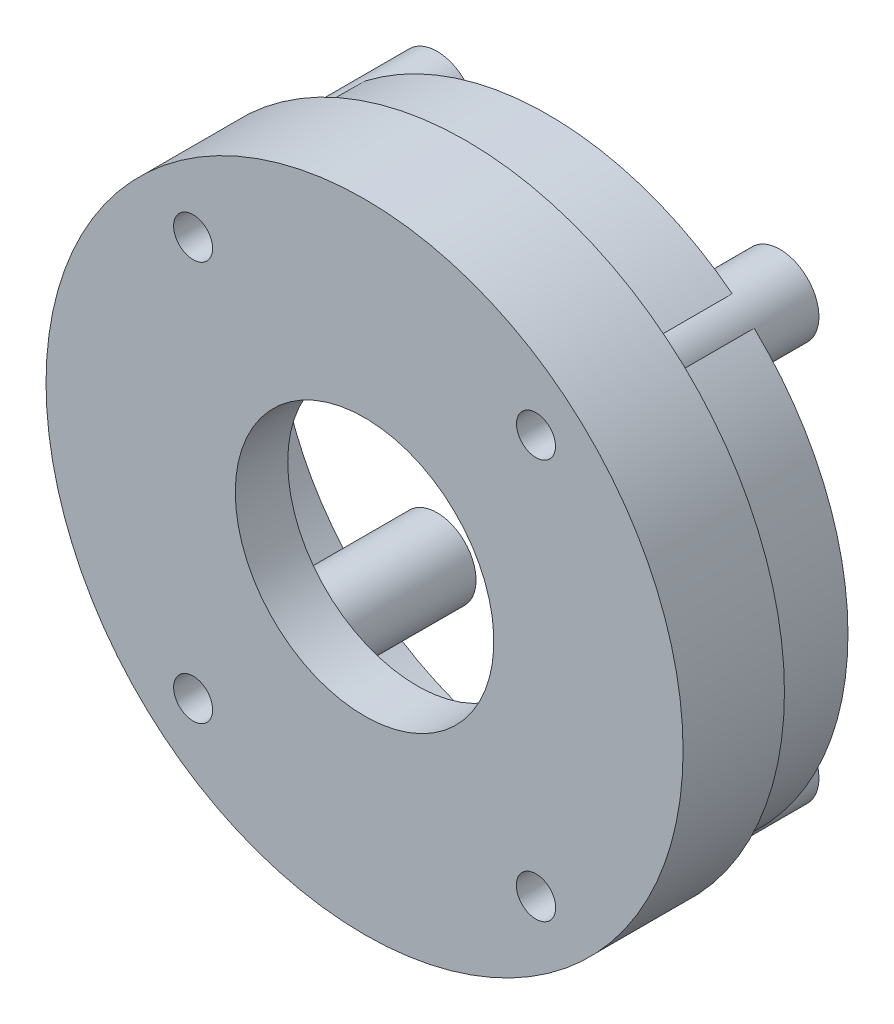
from build123d import *
from build123d.topology import SkipClean

# Parameters (mm, degrees)
SKETCH1_R               = 17
BOSS_EXTRUDE2_DEPTH     = 2.705
BOSS_EXTRUDE3_DEPTH     = 4.39
CUT_EXTRUDE2_DEPTH      = 25.642810311
CUT_EXTRUDE2_DEPTH_BACK = 25.642810311
SKETCH6_3_R             = 6.9
CUT_EXTRUDE3_START      = -4.11
SKETCH6_6_R             = 8.14
CUT_EXTRUDE3_DEPTH      = 4.11
SKETCH6_7_R             = 8.14
SKETCH6_7_R_2           = 6.9
CUT_EXTRUDE4_DEPTH      = 2.61
SKETCH6_12_R            = 1.04
SKETCH6_12_R_2          = 1.048997708
CUT_EXTRUDE5_DEPTH      = 25.642810311
SKETCH6_13_R            = 2.08
SKETCH6_13_R_2          = 1.04
SKETCH6_13_R_3          = 1.048997708
BOSS_EXTRUDE4_DEPTH     = 7.61


with BuildPart() as part:
    # Sketch1 → Boss-Extrude2 (new, symmetric)
    with BuildSketch(Plane.XY):
        Circle(SKETCH1_R)
    extrude(amount=BOSS_EXTRUDE2_DEPTH, both=True)

    # Sketch6 → Boss-Extrude3 (add)
    with BuildSketch(Plane(origin=(0, 0, -2.705), x_dir=(-1, 0, 0), z_dir=(0, 0, -1))):
        with BuildLine():
            Line((12.1, -0.595), (14.487787098, -0.595))
            ThreePointArc((14.487787098, -0.595), (13.46504185, -5.379837169), (10.909063856, -9.552084892))
            ThreePointArc((10.909063856, -9.552084892), (11.228265305, -10.577151075), (10.993770145, -11.624844859))
            ThreePointArc((10.993770145, -11.624844859), (16, 0), (10.993770145, 11.624844859))
            ThreePointArc((10.993770145, 11.624844859), (11.228265305, 10.577151075), (10.909063856, 9.552084892))
            ThreePointArc((10.909063856, 9.552084892), (13.46504185, 5.379837169), (14.487787098, 0.595))
            Line((14.487787098, 0.595), (12.1, 0.595))
            Line((12.1, 0.595), (12.1, -0.595))
        make_face()
        with BuildLine():
            ThreePointArc((-7.785906142, 12.23232053), (0, 14.5), (7.785906142, 12.23232053))
            ThreePointArc((7.785906142, 12.23232053), (8.750658086, 12.703387332), (9.821803695, 12.630604585))
            ThreePointArc((9.821803695, 12.630604585), (0, 16), (-9.821803695, 12.630604585))
            ThreePointArc((-9.821803695, 12.630604585), (-8.750658086, 12.703387332), (-7.785906142, 12.23232053))
        make_face()
        with BuildLine():
            ThreePointArc((9.821803695, -12.630604585), (8.750658086, -12.703387332), (7.785906142, -12.23232053))
            ThreePointArc((7.785906142, -12.23232053), (0, -14.5), (-7.785906142, -12.23232053))
            ThreePointArc((-7.785906142, -12.23232053), (-8.750658086, -12.703387332), (-9.821803695, -12.630604585))
            ThreePointArc((-9.821803695, -12.630604585), (0, -16), (9.821803695, -12.630604585))
        make_face()
        with BuildLine():
            ThreePointArc((-14.487787098, 0.595), (-13.46504185, 5.379837169), (-10.909063856, 9.552084892))
            ThreePointArc((-10.909063856, 9.552084892), (-11.228265305, 10.577151075), (-10.993770145, 11.624844859))
            ThreePointArc((-10.993770145, 11.624844859), (-16, 0), (-10.993770145, -11.624844859))
            ThreePointArc((-10.993770145, -11.624844859), (-11.228265305, -10.577151075), (-10.909063856, -9.552084892))
            ThreePointArc((-10.909063856, -9.552084892), (-13.46504185, -5.379837169), (-14.487787098, -0.595))
            Line((-14.487787098, -0.595), (-12.1, -0.595))
            Line((-12.1, -0.595), (-12.1, 0.595))
            Line((-12.1, 0.595), (-14.487787098, 0.595))
        make_face()
    extrude(amount=BOSS_EXTRUDE3_DEPTH)

    # Sketch6_3 → Cut-Extrude2 (cut, two sides: drawn at the far end of the back side and taken through both)
    with BuildSketch(Plane(origin=(0, 0, -2.705), x_dir=(-1, 0, 0), z_dir=(0, 0, -1)).offset(-CUT_EXTRUDE2_DEPTH_BACK)):
        Circle(SKETCH6_3_R)
    extrude(amount=CUT_EXTRUDE2_DEPTH + CUT_EXTRUDE2_DEPTH_BACK, mode=Mode.SUBTRACT)

    # Sketch6_6 → Cut-Extrude3 (cut)
    with BuildSketch(Plane(origin=(0, 0, -2.705), x_dir=(-1, 0, 0), z_dir=(0, 0, -1)).offset(CUT_EXTRUDE3_START)):
        with BuildLine():
            Line((12.1, 0.595), (14.487787098, 0.595))
            ThreePointArc((14.487787098, 0.595), (13.46504185, 5.379837169), (10.909063856, 9.552084892))
            ThreePointArc((10.909063856, 9.552084892), (7.795409253, 9.08363884), (7.785906142, 12.23232053))
            ThreePointArc((7.785906142, 12.23232053), (0, 14.5), (-7.785906142, 12.23232053))
            ThreePointArc((-7.785906142, 12.23232053), (-7.257420382, 11.524951045), (-7.07, 10.662082348))
            ThreePointArc((-7.07, 10.662082348), (-8.572268583, 8.663926596), (-10.909063856, 9.552084892))
            ThreePointArc((-10.909063856, 9.552084892), (-13.46504185, 5.379837169), (-14.487787098, 0.595))
            Line((-14.487787098, 0.595), (-12.1, 0.595))
            Line((-12.1, 0.595), (-12.1, -0.595))
            Line((-12.1, -0.595), (-14.487787098, -0.595))
            ThreePointArc((-14.487787098, -0.595), (-13.46504185, -5.379837169), (-10.909063856, -9.552084892))
            ThreePointArc((-10.909063856, -9.552084892), (-8.572268583, -8.663926596), (-7.07, -10.662082348))
            ThreePointArc((-7.07, -10.662082348), (-7.257420382, -11.524951045), (-7.785906142, -12.23232053))
            ThreePointArc((-7.785906142, -12.23232053), (0, -14.5), (7.785906142, -12.23232053))
            ThreePointArc((7.785906142, -12.23232053), (7.795409253, -9.08363884), (10.909063856, -9.552084892))
            ThreePointArc((10.909063856, -9.552084892), (13.46504185, -5.379837169), (14.487787098, -0.595))
            Line((14.487787098, -0.595), (12.1, -0.595))
            Line((12.1, -0.595), (12.1, 0.595))
        make_face()
        Circle(SKETCH6_6_R, mode=Mode.SUBTRACT)
    extrude(amount=CUT_EXTRUDE3_DEPTH, mode=Mode.SUBTRACT)

    # Sketch6_7 → Cut-Extrude4 (cut)
    with BuildSketch(Plane(origin=(0, 0, -2.705), x_dir=(-1, 0, 0), z_dir=(0, 0, -1))):
        Circle(SKETCH6_7_R)
        Circle(SKETCH6_7_R_2, mode=Mode.SUBTRACT)
    extrude(amount=-CUT_EXTRUDE4_DEPTH, mode=Mode.SUBTRACT)

    # Sketch6_12 → Cut-Extrude5 (cut, through all)
    with BuildSketch(Plane(origin=(0, 0, -2.705), x_dir=(-1, 0, 0), z_dir=(0, 0, -1))):
        with Locations((9.15, -10.662082348)):
            Circle(SKETCH6_12_R)
        with Locations((-9.15, -10.662082348)):
            Circle(SKETCH6_12_R_2)
        with Locations((9.15, 10.662082348)):
            Circle(SKETCH6_12_R)
        with Locations((-9.15, 10.662082348)):
            Circle(SKETCH6_12_R)
    extrude(amount=-CUT_EXTRUDE5_DEPTH, mode=Mode.SUBTRACT)

    # Sketch6_13 → Boss-Extrude4 (add)
    # profile 1 of 4: a face of its own
    with SkipClean():  # the faces are left unmerged after this step: merging them gives an invalid solid
        with BuildSketch(Plane(origin=(0, 0, -2.705), x_dir=(-1, 0, 0), z_dir=(0, 0, -1))):
            with Locations((9.15, 10.662082348)):
                Circle(SKETCH6_13_R)
            with Locations((9.15, 10.662082348)):
                Circle(SKETCH6_13_R_2, mode=Mode.SUBTRACT)
        # profile 2 of 4: a face of its own
        with BuildSketch(Plane(origin=(0, 0, -2.705), x_dir=(-1, 0, 0), z_dir=(0, 0, -1))):
            with Locations((9.15, -10.662082348)):
                Circle(SKETCH6_13_R)
            with Locations((9.15, -10.662082348)):
                Circle(SKETCH6_13_R_2, mode=Mode.SUBTRACT)
        # profile 3 of 4: a face of its own
        with BuildSketch(Plane(origin=(0, 0, -2.705), x_dir=(-1, 0, 0), z_dir=(0, 0, -1))):
            with Locations((-9.15, 10.662082348)):
                Circle(SKETCH6_13_R)
            with Locations((-9.15, 10.662082348)):
                Circle(SKETCH6_13_R_2, mode=Mode.SUBTRACT)
        # profile 4 of 4: a face of its own
        with BuildSketch(Plane(origin=(0, 0, -2.705), x_dir=(-1, 0, 0), z_dir=(0, 0, -1))):
            with Locations((-9.15, -10.662082348)):
                Circle(SKETCH6_13_R)
            with Locations((-9.15, -10.662082348)):
                Circle(SKETCH6_13_R_3, mode=Mode.SUBTRACT)
        extrude(amount=BOSS_EXTRUDE4_DEPTH)


solid = part.part
